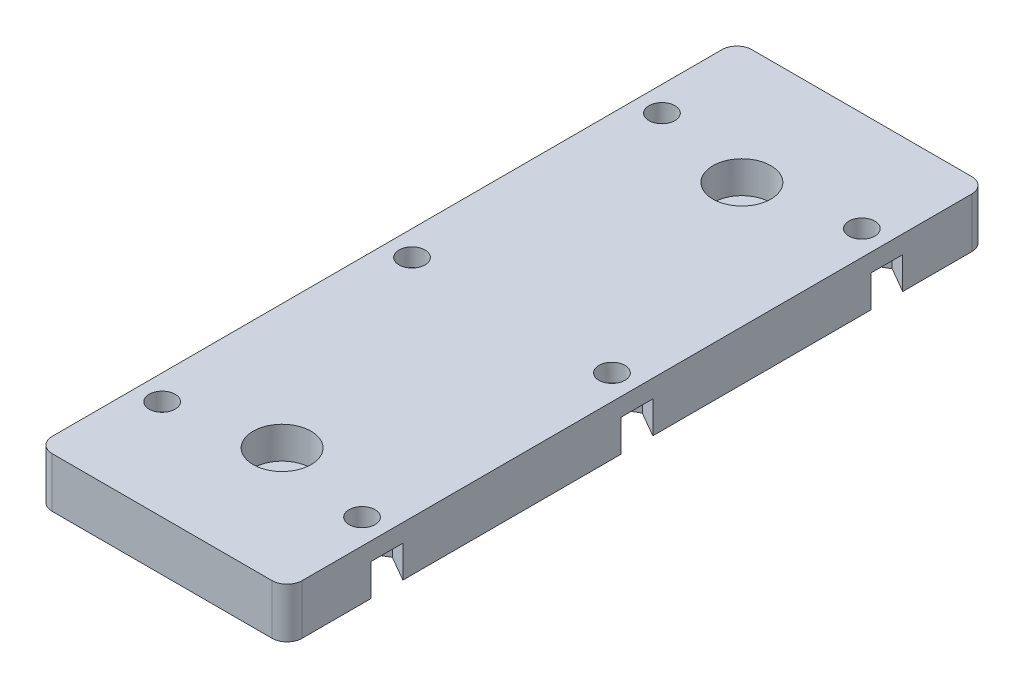
from build123d import *

# Parameters (mm, degrees)
SKETCH_1_W          = 25
SKETCH_1_H          = 70
SKETCH_1_R          = 1.3
SKETCH_1_R_2        = 1.65
EXTRUDE_1_DEPTH     = 5
SKETCH_2_R          = 2.9
CUT_EXTRUDE_1_DEPTH = 3.2
CUT_EXTRUDE_2_DEPTH = 3.2
FILLET_1_R          = 1.5
EXTRUDE_2_DEPTH     = 3


with BuildPart() as part:
    # 草图1 → 凸台-拉伸1 (new body)
    with BuildSketch(Plane(origin=(0, 0, 0), x_dir=(1, 0, 0), z_dir=(0, 1, 0))):
        Rectangle(SKETCH_1_W, SKETCH_1_H)
        with Locations((10, 25)):
            Circle(SKETCH_1_R, mode=Mode.SUBTRACT)
        with Locations((10, 0)):
            Circle(SKETCH_1_R, mode=Mode.SUBTRACT)
        with Locations((10, -25)):
            Circle(SKETCH_1_R, mode=Mode.SUBTRACT)
        with Locations((0, 23)):
            Circle(SKETCH_1_R_2, mode=Mode.SUBTRACT)
        with Locations((0, -23)):
            Circle(SKETCH_1_R_2, mode=Mode.SUBTRACT)
        with Locations((-10, 25)):
            Circle(SKETCH_1_R, mode=Mode.SUBTRACT)
        with Locations((-10, 0)):
            Circle(SKETCH_1_R, mode=Mode.SUBTRACT)
        with Locations((-10, -25)):
            Circle(SKETCH_1_R, mode=Mode.SUBTRACT)
    extrude(amount=EXTRUDE_1_DEPTH)

    # 草图2 → 切除-拉伸1 (cut)
    with BuildSketch(Plane(origin=(0, 5, 0), x_dir=(1, 0, 0), z_dir=(0, 1, 0))):
        with Locations((0, 23)):
            Circle(SKETCH_2_R)
        with Locations((0, -23)):
            Circle(SKETCH_2_R)
    extrude(amount=-CUT_EXTRUDE_1_DEPTH, mode=Mode.SUBTRACT)

    # 草图3 → 切除-拉伸2 (cut)
    with BuildSketch(Plane.XZ):
        Polygon((-7.375, 23.484455543), (-7.375, 26.515544457), (-10, 28.031088913), (-12.625, 26.515544457), (-12.625, 23.484455543), (-10, 21.968911087), align=None)
        Polygon((10, 28.031088913), (7.375, 26.515544457), (7.375, 23.484455543), (10, 21.968911087), (12.625, 23.484455543), (12.625, 26.515544457), align=None)
        Polygon((10, 3.031088913), (7.375, 1.515544457), (7.375, -1.515544457), (10, -3.031088913), (12.625, -1.515544457), (12.625, 1.515544457), align=None)
        Polygon((-10, 3.031088913), (-12.625, 1.515544457), (-12.625, -1.515544457), (-10, -3.031088913), (-7.375, -1.515544457), (-7.375, 1.515544457), align=None)
        Polygon((-7.375, -26.515544457), (-7.375, -23.484455543), (-10, -21.968911087), (-12.625, -23.484455543), (-12.625, -26.515544457), (-10, -28.031088913), align=None)
        Polygon((10, -21.968911087), (7.375, -23.484455543), (7.375, -26.515544457), (10, -28.031088913), (12.625, -26.515544457), (12.625, -23.484455543), align=None)
    extrude(amount=-CUT_EXTRUDE_2_DEPTH, mode=Mode.SUBTRACT)

    # 圆角1
    fillet_1_edges = [part.edges().sort_by_distance(p)[0] for p in [
        (12.5, 2.5, 35),
        (-12.5, 2.5, 35),
        (-12.5, 2.5, -35),
        (12.5, 2.5, -35),
    ]]
    fillet(fillet_1_edges, radius=FILLET_1_R)

    # 草图4 → 凸台-拉伸2 (add, symmetric)
    with BuildSketch(Plane(origin=(0, 0, 0), x_dir=(0, 0, -1), z_dir=(1, 0, 0))):
        Polygon((-34, 0), (-27, 0), (-29, -2), (-32, -2), align=None)
        Polygon((29, -2), (32, -2), (34, 0), (27, 0), align=None)
    extrude(amount=EXTRUDE_2_DEPTH, both=True)


solid = part.part
